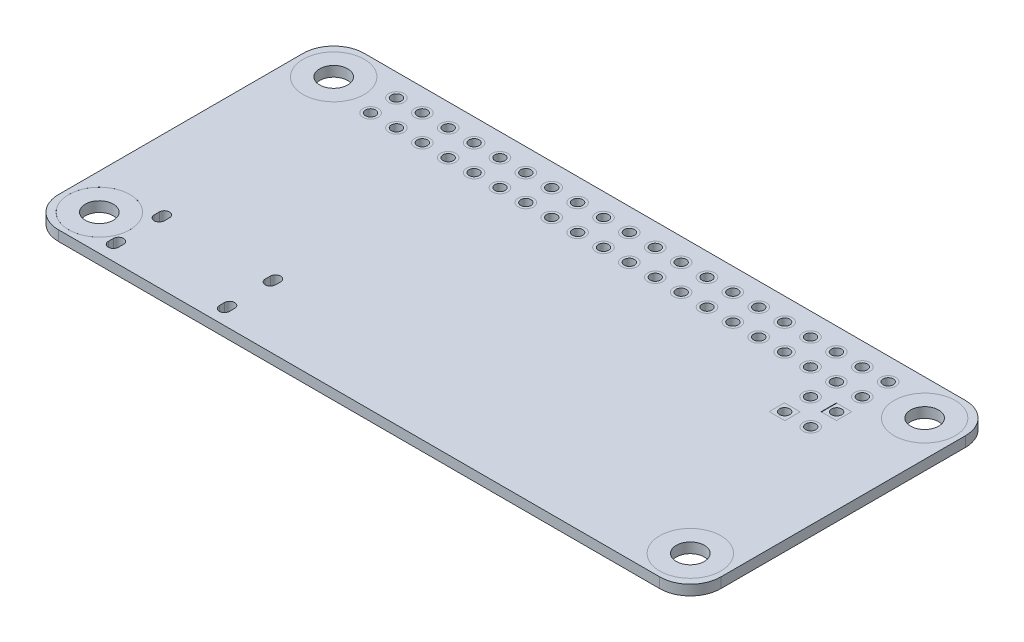
from build123d import *

# Parameters (mm, degrees)
SKETCH1_R             = 3
SKETCH1_R_2           = 0.75
SKETCH1_W             = 1.5
SKETCH1_H             = 1.5
BOSS_EXTRUDE1_DEPTH   = 1
SKETCH2_R             = 0.75
SKETCH2_R_2           = 0.5
BOSS_EXTRUDE2_DEPTH   = 1
LPATTERN2_COUNT       = 20
LPATTERN2_PITCH       = 2.54
LPATTERN2_2_COUNT     = 2
LPATTERN2_2_PITCH     = 2.54
SKETCH3_R             = 0.75
SKETCH3_R_2           = 0.5
BOSS_EXTRUDE3_DEPTH   = 1
BOSS_EXTRUDE3_2_DEPTH = 1
SKETCH3_W             = 1.541222488
SKETCH3_H             = 1.5
BOSS_EXTRUDE3_3_DEPTH = 1
SKETCH3_W_2           = 1.458777511
BOSS_EXTRUDE3_4_DEPTH = 1
SKETCH4_R             = 3
SKETCH4_R_2           = 1.375
BOSS_EXTRUDE4_DEPTH   = 1
CUT_EXTRUDE1_DEPTH    = 1


with BuildPart() as part:
    # Sketch1 → Boss-Extrude1 (new body)
    with BuildSketch(Plane(origin=(0, 0, 0), x_dir=(1, 0, 0), z_dir=(0, 1, 0))):
        with BuildLine():
            Line((-29.5, -15), (29.5, -15))
            ThreePointArc((29.5, -15), (31.621320344, -14.121320344), (32.5, -12))
            Line((32.5, -12), (32.5, 12))
            ThreePointArc((32.5, 12), (31.621320344, 14.121320344), (29.5, 15))
            Line((29.5, 15), (-29.5, 15))
            ThreePointArc((-29.5, 15), (-31.621320344, 14.121320344), (-32.5, 12))
            Line((-32.5, 12), (-32.5, -12))
            ThreePointArc((-32.5, -12), (-31.621320344, -14.121320344), (-29.5, -15))
        make_face()
        with Locations((-29, 11.5)):
            Circle(SKETCH1_R, mode=Mode.SUBTRACT)
        with Locations((-29, -11.5)):
            Circle(SKETCH1_R, mode=Mode.SUBTRACT)
        with Locations((29, -11.5)):
            Circle(SKETCH1_R, mode=Mode.SUBTRACT)
        with Locations((-24.13, 12.787653136)):
            Circle(SKETCH1_R_2, mode=Mode.SUBTRACT)
        with Locations((-21.59, 12.787653136)):
            Circle(SKETCH1_R_2, mode=Mode.SUBTRACT)
        with Locations((-19.05, 12.787653136)):
            Circle(SKETCH1_R_2, mode=Mode.SUBTRACT)
        with Locations((-16.51, 12.787653136)):
            Circle(SKETCH1_R_2, mode=Mode.SUBTRACT)
        with Locations((-13.97, 12.787653136)):
            Circle(SKETCH1_R_2, mode=Mode.SUBTRACT)
        with Locations((-11.43, 12.787653136)):
            Circle(SKETCH1_R_2, mode=Mode.SUBTRACT)
        with Locations((-8.89, 12.787653136)):
            Circle(SKETCH1_R_2, mode=Mode.SUBTRACT)
        with Locations((-6.35, 12.787653136)):
            Circle(SKETCH1_R_2, mode=Mode.SUBTRACT)
        with Locations((-3.81, 12.787653136)):
            Circle(SKETCH1_R_2, mode=Mode.SUBTRACT)
        with Locations((-1.27, 12.787653136)):
            Circle(SKETCH1_R_2, mode=Mode.SUBTRACT)
        with Locations((1.27, 12.787653136)):
            Circle(SKETCH1_R_2, mode=Mode.SUBTRACT)
        with Locations((3.81, 12.787653136)):
            Circle(SKETCH1_R_2, mode=Mode.SUBTRACT)
        with Locations((6.35, 12.787653136)):
            Circle(SKETCH1_R_2, mode=Mode.SUBTRACT)
        with Locations((8.89, 12.787653136)):
            Circle(SKETCH1_R_2, mode=Mode.SUBTRACT)
        with Locations((11.43, 12.787653136)):
            Circle(SKETCH1_R_2, mode=Mode.SUBTRACT)
        with Locations((13.97, 12.787653136)):
            Circle(SKETCH1_R_2, mode=Mode.SUBTRACT)
        with Locations((16.51, 12.787653136)):
            Circle(SKETCH1_R_2, mode=Mode.SUBTRACT)
        with Locations((19.05, 12.787653136)):
            Circle(SKETCH1_R_2, mode=Mode.SUBTRACT)
        with Locations((21.59, 12.787653136)):
            Circle(SKETCH1_R_2, mode=Mode.SUBTRACT)
        with Locations((24.13, 12.787653136)):
            Circle(SKETCH1_R_2, mode=Mode.SUBTRACT)
        with Locations((-21.59, 10.247653136)):
            Circle(SKETCH1_R_2, mode=Mode.SUBTRACT)
        with Locations((-19.05, 10.247653136)):
            Circle(SKETCH1_R_2, mode=Mode.SUBTRACT)
        with Locations((-16.51, 10.247653136)):
            Circle(SKETCH1_R_2, mode=Mode.SUBTRACT)
        with Locations((-13.97, 10.247653136)):
            Circle(SKETCH1_R_2, mode=Mode.SUBTRACT)
        with Locations((-11.43, 10.247653136)):
            Circle(SKETCH1_R_2, mode=Mode.SUBTRACT)
        with Locations((-8.89, 10.247653136)):
            Circle(SKETCH1_R_2, mode=Mode.SUBTRACT)
        with Locations((-6.35, 10.247653136)):
            Circle(SKETCH1_R_2, mode=Mode.SUBTRACT)
        with Locations((-3.81, 10.247653136)):
            Circle(SKETCH1_R_2, mode=Mode.SUBTRACT)
        with Locations((-1.27, 10.247653136)):
            Circle(SKETCH1_R_2, mode=Mode.SUBTRACT)
        with Locations((1.27, 10.247653136)):
            Circle(SKETCH1_R_2, mode=Mode.SUBTRACT)
        with Locations((3.81, 10.247653136)):
            Circle(SKETCH1_R_2, mode=Mode.SUBTRACT)
        with Locations((6.35, 10.247653136)):
            Circle(SKETCH1_R_2, mode=Mode.SUBTRACT)
        with Locations((8.89, 10.247653136)):
            Circle(SKETCH1_R_2, mode=Mode.SUBTRACT)
        with Locations((11.43, 10.247653136)):
            Circle(SKETCH1_R_2, mode=Mode.SUBTRACT)
        with Locations((13.97, 10.247653136)):
            Circle(SKETCH1_R_2, mode=Mode.SUBTRACT)
        with Locations((16.51, 10.247653136)):
            Circle(SKETCH1_R_2, mode=Mode.SUBTRACT)
        with Locations((19.05, 10.247653136)):
            Circle(SKETCH1_R_2, mode=Mode.SUBTRACT)
        with Locations((21.59, 10.247653136)):
            Circle(SKETCH1_R_2, mode=Mode.SUBTRACT)
        with Locations((24.13, 10.247653136)):
            Circle(SKETCH1_R_2, mode=Mode.SUBTRACT)
        with Locations((-24.13, 10.247653136)):
            Circle(SKETCH1_R_2, mode=Mode.SUBTRACT)
        with Locations((21.59002512, 7.707653136)):
            Circle(SKETCH1_R_2, mode=Mode.SUBTRACT)
        with Locations((24.150636364, 5.167736764)):
            Circle(SKETCH1_R_2, mode=Mode.SUBTRACT)
        with Locations((29, 11.5)):
            Circle(SKETCH1_R, mode=Mode.SUBTRACT)
        with Locations((24.13002512, 7.707653136)):
            Rectangle(SKETCH1_W, SKETCH1_H, mode=Mode.SUBTRACT)
        with Locations((21.610636364, 5.167736764)):
            Rectangle(SKETCH1_W, SKETCH1_H, mode=Mode.SUBTRACT)
    extrude(amount=BOSS_EXTRUDE1_DEPTH)

    # Sketch5 → Cut-Extrude1 (cut)
    with BuildSketch(Plane.XZ):
        with BuildLine():
            Line((-26.078842351, 13.039495396), (-26.078842351, 13.539495396))
            ThreePointArc((-26.078842351, 13.539495396), (-25.578842351, 14.039495396), (-25.078842351, 13.539495396))
            Line((-25.078842351, 13.539495396), (-25.078842351, 13.039495396))
            ThreePointArc((-25.078842351, 13.039495396), (-25.578842351, 12.539495396), (-26.078842351, 13.039495396))
        make_face()
        with BuildLine():
            Line((-15.178842351, 13.039495396), (-15.178842351, 13.539495396))
            ThreePointArc((-15.178842351, 13.539495396), (-14.678842351, 14.039495396), (-14.178842351, 13.539495396))
            Line((-14.178842351, 13.539495396), (-14.178842351, 13.039495396))
            ThreePointArc((-14.178842351, 13.039495396), (-14.678842351, 12.539495396), (-15.178842351, 13.039495396))
        make_face()
        with BuildLine():
            Line((-15.178842351, 8.539495396), (-15.178842351, 9.039495396))
            ThreePointArc((-15.178842351, 9.039495396), (-14.678842351, 9.539495396), (-14.178842351, 9.039495396))
            Line((-14.178842351, 9.039495396), (-14.178842351, 8.539495396))
            ThreePointArc((-14.178842351, 8.539495396), (-14.678842351, 8.039495396), (-15.178842351, 8.539495396))
        make_face()
        with BuildLine():
            Line((-26.078842351, 8.539495396), (-26.078842351, 9.039495396))
            ThreePointArc((-26.078842351, 9.039495396), (-25.578842351, 9.539495396), (-25.078842351, 9.039495396))
            Line((-25.078842351, 9.039495396), (-25.078842351, 8.539495396))
            ThreePointArc((-25.078842351, 8.539495396), (-25.578842351, 8.039495396), (-26.078842351, 8.539495396))
        make_face()
    extrude(amount=-CUT_EXTRUDE1_DEPTH, mode=Mode.SUBTRACT)


with BuildPart() as body_2:
    # Sketch2 → Boss-Extrude2 (new body)
    with BuildSketch(Plane(origin=(0, 0, 0), x_dir=(1, 0, 0), z_dir=(0, 1, 0))):
        with Locations((-24.13, 12.787653136)):
            Circle(SKETCH2_R)
        with Locations((-24.13, 12.787653136)):
            Circle(SKETCH2_R_2, mode=Mode.SUBTRACT)
    extrude(amount=BOSS_EXTRUDE2_DEPTH)


with BuildPart() as lpattern2_1:
    # LPattern2: pattern copy
    add(body_2.part.moved(Location(Vector(1, 0, 0) * (1 * LPATTERN2_PITCH))))


with BuildPart() as lpattern2_2:
    # LPattern2: pattern copy
    add(body_2.part.moved(Location(Vector(1, 0, 0) * (2 * LPATTERN2_PITCH))))


with BuildPart() as lpattern2_3:
    # LPattern2: pattern copy
    add(body_2.part.moved(Location(Vector(1, 0, 0) * (3 * LPATTERN2_PITCH))))


with BuildPart() as lpattern2_4:
    # LPattern2: pattern copy
    add(body_2.part.moved(Location(Vector(1, 0, 0) * (4 * LPATTERN2_PITCH))))


with BuildPart() as lpattern2_5:
    # LPattern2: pattern copy
    add(body_2.part.moved(Location(Vector(1, 0, 0) * (5 * LPATTERN2_PITCH))))


with BuildPart() as lpattern2_6:
    # LPattern2: pattern copy
    add(body_2.part.moved(Location(Vector(1, 0, 0) * (6 * LPATTERN2_PITCH))))


with BuildPart() as lpattern2_7:
    # LPattern2: pattern copy
    add(body_2.part.moved(Location(Vector(1, 0, 0) * (7 * LPATTERN2_PITCH))))


with BuildPart() as lpattern2_8:
    # LPattern2: pattern copy
    add(body_2.part.moved(Location(Vector(1, 0, 0) * (8 * LPATTERN2_PITCH))))


with BuildPart() as lpattern2_9:
    # LPattern2: pattern copy
    add(body_2.part.moved(Location(Vector(1, 0, 0) * (9 * LPATTERN2_PITCH))))


with BuildPart() as lpattern2_10:
    # LPattern2: pattern copy
    add(body_2.part.moved(Location(Vector(1, 0, 0) * (10 * LPATTERN2_PITCH))))


with BuildPart() as lpattern2_11:
    # LPattern2: pattern copy
    add(body_2.part.moved(Location(Vector(1, 0, 0) * (11 * LPATTERN2_PITCH))))


with BuildPart() as lpattern2_12:
    # LPattern2: pattern copy
    add(body_2.part.moved(Location(Vector(1, 0, 0) * (12 * LPATTERN2_PITCH))))


with BuildPart() as lpattern2_13:
    # LPattern2: pattern copy
    add(body_2.part.moved(Location(Vector(1, 0, 0) * (13 * LPATTERN2_PITCH))))


with BuildPart() as lpattern2_14:
    # LPattern2: pattern copy
    add(body_2.part.moved(Location(Vector(1, 0, 0) * (14 * LPATTERN2_PITCH))))


with BuildPart() as lpattern2_15:
    # LPattern2: pattern copy
    add(body_2.part.moved(Location(Vector(1, 0, 0) * (15 * LPATTERN2_PITCH))))


with BuildPart() as lpattern2_16:
    # LPattern2: pattern copy
    add(body_2.part.moved(Location(Vector(1, 0, 0) * (16 * LPATTERN2_PITCH))))


with BuildPart() as lpattern2_17:
    # LPattern2: pattern copy
    add(body_2.part.moved(Location(Vector(1, 0, 0) * (17 * LPATTERN2_PITCH))))


with BuildPart() as lpattern2_18:
    # LPattern2: pattern copy
    add(body_2.part.moved(Location(Vector(1, 0, 0) * (18 * LPATTERN2_PITCH))))


with BuildPart() as lpattern2_19:
    # LPattern2: pattern copy
    add(body_2.part.moved(Location(Vector(1, 0, 0) * (19 * LPATTERN2_PITCH))))


with BuildPart() as lpattern2_2_1:
    # LPattern2 2: pattern copy
    add(body_2.part.moved(Location(Vector(0, 0, 1) * (1 * LPATTERN2_2_PITCH))))


with BuildPart() as lpattern2_2_2:
    # LPattern2 2: pattern copy
    add(lpattern2_1.part.moved(Location(Vector(0, 0, 1) * (1 * LPATTERN2_2_PITCH))))


with BuildPart() as lpattern2_2_3:
    # LPattern2 2: pattern copy
    add(lpattern2_2.part.moved(Location(Vector(0, 0, 1) * (1 * LPATTERN2_2_PITCH))))


with BuildPart() as lpattern2_2_4:
    # LPattern2 2: pattern copy
    add(lpattern2_3.part.moved(Location(Vector(0, 0, 1) * (1 * LPATTERN2_2_PITCH))))


with BuildPart() as lpattern2_2_5:
    # LPattern2 2: pattern copy
    add(lpattern2_4.part.moved(Location(Vector(0, 0, 1) * (1 * LPATTERN2_2_PITCH))))


with BuildPart() as lpattern2_2_6:
    # LPattern2 2: pattern copy
    add(lpattern2_5.part.moved(Location(Vector(0, 0, 1) * (1 * LPATTERN2_2_PITCH))))


with BuildPart() as lpattern2_2_7:
    # LPattern2 2: pattern copy
    add(lpattern2_6.part.moved(Location(Vector(0, 0, 1) * (1 * LPATTERN2_2_PITCH))))


with BuildPart() as lpattern2_2_8:
    # LPattern2 2: pattern copy
    add(lpattern2_7.part.moved(Location(Vector(0, 0, 1) * (1 * LPATTERN2_2_PITCH))))


with BuildPart() as lpattern2_2_9:
    # LPattern2 2: pattern copy
    add(lpattern2_8.part.moved(Location(Vector(0, 0, 1) * (1 * LPATTERN2_2_PITCH))))


with BuildPart() as lpattern2_2_10:
    # LPattern2 2: pattern copy
    add(lpattern2_9.part.moved(Location(Vector(0, 0, 1) * (1 * LPATTERN2_2_PITCH))))


with BuildPart() as lpattern2_2_11:
    # LPattern2 2: pattern copy
    add(lpattern2_10.part.moved(Location(Vector(0, 0, 1) * (1 * LPATTERN2_2_PITCH))))


with BuildPart() as lpattern2_2_12:
    # LPattern2 2: pattern copy
    add(lpattern2_11.part.moved(Location(Vector(0, 0, 1) * (1 * LPATTERN2_2_PITCH))))


with BuildPart() as lpattern2_2_13:
    # LPattern2 2: pattern copy
    add(lpattern2_12.part.moved(Location(Vector(0, 0, 1) * (1 * LPATTERN2_2_PITCH))))


with BuildPart() as lpattern2_2_14:
    # LPattern2 2: pattern copy
    add(lpattern2_13.part.moved(Location(Vector(0, 0, 1) * (1 * LPATTERN2_2_PITCH))))


with BuildPart() as lpattern2_2_15:
    # LPattern2 2: pattern copy
    add(lpattern2_14.part.moved(Location(Vector(0, 0, 1) * (1 * LPATTERN2_2_PITCH))))


with BuildPart() as lpattern2_2_16:
    # LPattern2 2: pattern copy
    add(lpattern2_15.part.moved(Location(Vector(0, 0, 1) * (1 * LPATTERN2_2_PITCH))))


with BuildPart() as lpattern2_2_17:
    # LPattern2 2: pattern copy
    add(lpattern2_16.part.moved(Location(Vector(0, 0, 1) * (1 * LPATTERN2_2_PITCH))))


with BuildPart() as lpattern2_2_18:
    # LPattern2 2: pattern copy
    add(lpattern2_17.part.moved(Location(Vector(0, 0, 1) * (1 * LPATTERN2_2_PITCH))))


with BuildPart() as lpattern2_2_19:
    # LPattern2 2: pattern copy
    add(lpattern2_18.part.moved(Location(Vector(0, 0, 1) * (1 * LPATTERN2_2_PITCH))))


with BuildPart() as lpattern2_2_20:
    # LPattern2 2: pattern copy
    add(lpattern2_19.part.moved(Location(Vector(0, 0, 1) * (1 * LPATTERN2_2_PITCH))))


with BuildPart() as body_42:
    # Sketch3 → Boss-Extrude3 (new body)
    with BuildSketch(Plane(origin=(0, 0, 0), x_dir=(1, 0, 0), z_dir=(0, 1, 0))):
        with Locations((21.59002512, 7.707653136)):
            Circle(SKETCH3_R)
        with Locations((21.59002512, 7.707653136)):
            Circle(SKETCH3_R_2, mode=Mode.SUBTRACT)
    extrude(amount=BOSS_EXTRUDE3_DEPTH)


with BuildPart() as body_43:
    # Sketch3 → Boss-Extrude3 2 (new body)
    with BuildSketch(Plane(origin=(0, 0, 0), x_dir=(1, 0, 0), z_dir=(0, 1, 0))):
        with Locations((24.150636364, 5.167736764)):
            Circle(SKETCH3_R)
        with Locations((24.150636364, 5.167736764)):
            Circle(SKETCH3_R_2, mode=Mode.SUBTRACT)
    extrude(amount=BOSS_EXTRUDE3_2_DEPTH)


with BuildPart() as body_44:
    # Sketch3 → Boss-Extrude3 3 (new body)
    with BuildSketch(Plane(origin=(0, 0, 0), x_dir=(1, 0, 0), z_dir=(0, 1, 0))):
        with Locations((21.59002512, 5.167736764)):
            Rectangle(SKETCH3_W, SKETCH3_H)
        with Locations((21.59002512, 5.167736764)):
            Circle(SKETCH3_R_2, mode=Mode.SUBTRACT)
    extrude(amount=BOSS_EXTRUDE3_3_DEPTH)


with BuildPart() as body_45:
    # Sketch3 → Boss-Extrude3 4 (new body)
    with BuildSketch(Plane(origin=(0, 0, 0), x_dir=(1, 0, 0), z_dir=(0, 1, 0))):
        with Locations((24.150636365, 7.707653136)):
            Rectangle(SKETCH3_W_2, SKETCH3_H)
        with Locations((24.150636364, 7.707653136)):
            Circle(SKETCH3_R_2, mode=Mode.SUBTRACT)
    extrude(amount=BOSS_EXTRUDE3_4_DEPTH)


with BuildPart() as body_46:
    # Sketch4 → Boss-Extrude4 (new body)
    with BuildSketch(Plane(origin=(0, 0, 0), x_dir=(1, 0, 0), z_dir=(0, 1, 0))):
        with Locations((-29, 11.5)):
            Circle(SKETCH4_R)
        with Locations((-29, 11.5)):
            Circle(SKETCH4_R_2, mode=Mode.SUBTRACT)
    extrude(amount=BOSS_EXTRUDE4_DEPTH)


with BuildPart() as body_47:
    # Mirror1: mirrored copy
    add(body_46.part.mirror(Plane(origin=(0, 0, 0), x_dir=(0, 0, 1), z_dir=(1, 0, 0))))


with BuildPart() as body_48:
    # Mirror2: mirrored copy
    add(body_46.part.mirror(Plane.XY))


with BuildPart() as body_49:
    # Mirror2 2: mirrored copy
    add(body_47.part.mirror(Plane.XY))


solid = Compound([part.part, body_2.part, lpattern2_1.part, lpattern2_2.part, lpattern2_3.part, lpattern2_4.part, lpattern2_5.part, lpattern2_6.part, lpattern2_7.part, lpattern2_8.part, lpattern2_9.part, lpattern2_10.part, lpattern2_11.part, lpattern2_12.part, lpattern2_13.part, lpattern2_14.part, lpattern2_15.part, lpattern2_16.part, lpattern2_17.part, lpattern2_18.part, lpattern2_19.part, lpattern2_2_1.part, lpattern2_2_2.part, lpattern2_2_3.part, lpattern2_2_4.part, lpattern2_2_5.part, lpattern2_2_6.part, lpattern2_2_7.part, lpattern2_2_8.part, lpattern2_2_9.part, lpattern2_2_10.part, lpattern2_2_11.part, lpattern2_2_12.part, lpattern2_2_13.part, lpattern2_2_14.part, lpattern2_2_15.part, lpattern2_2_16.part, lpattern2_2_17.part, lpattern2_2_18.part, lpattern2_2_19.part, lpattern2_2_20.part, body_42.part, body_43.part, body_44.part, body_45.part, body_46.part, body_47.part, body_48.part, body_49.part])
